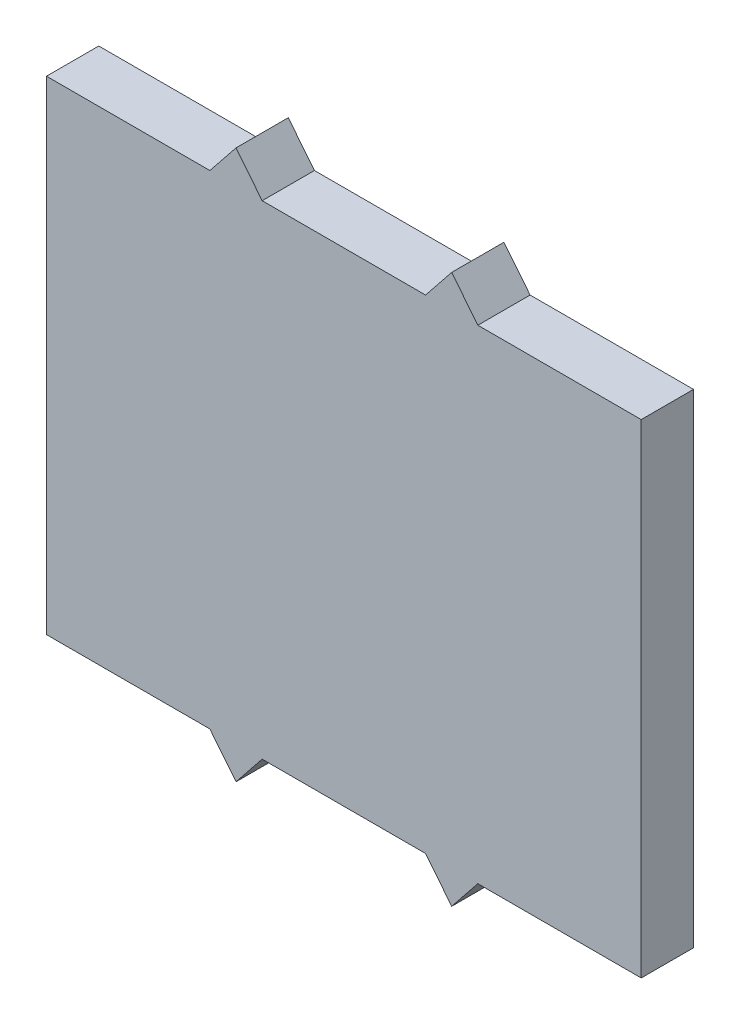
from build123d import *

# Parameters (mm, degrees)
SKETCH1_W   = 45.5
SKETCH1_H   = 37
BASIS_DEPTH = 4


with BuildPart() as part:
    # Sketch1 → Basis (new body)
    with BuildSketch(Plane.XY):
        with Locations((22.75, 18.5)):
            Rectangle(SKETCH1_W, SKETCH1_H)
        Polygon((14.5, 39.5), (12.5, 37), (16.5, 37), align=None)
        Polygon((31, 39.5), (29, 37), (33, 37), align=None)
        Polygon((16.5, 0), (12.5, 0), (14.5, -2.5), align=None)
        Polygon((33, 0), (29, 0), (31, -2.5), align=None)
    extrude(amount=BASIS_DEPTH)


solid = part.part
